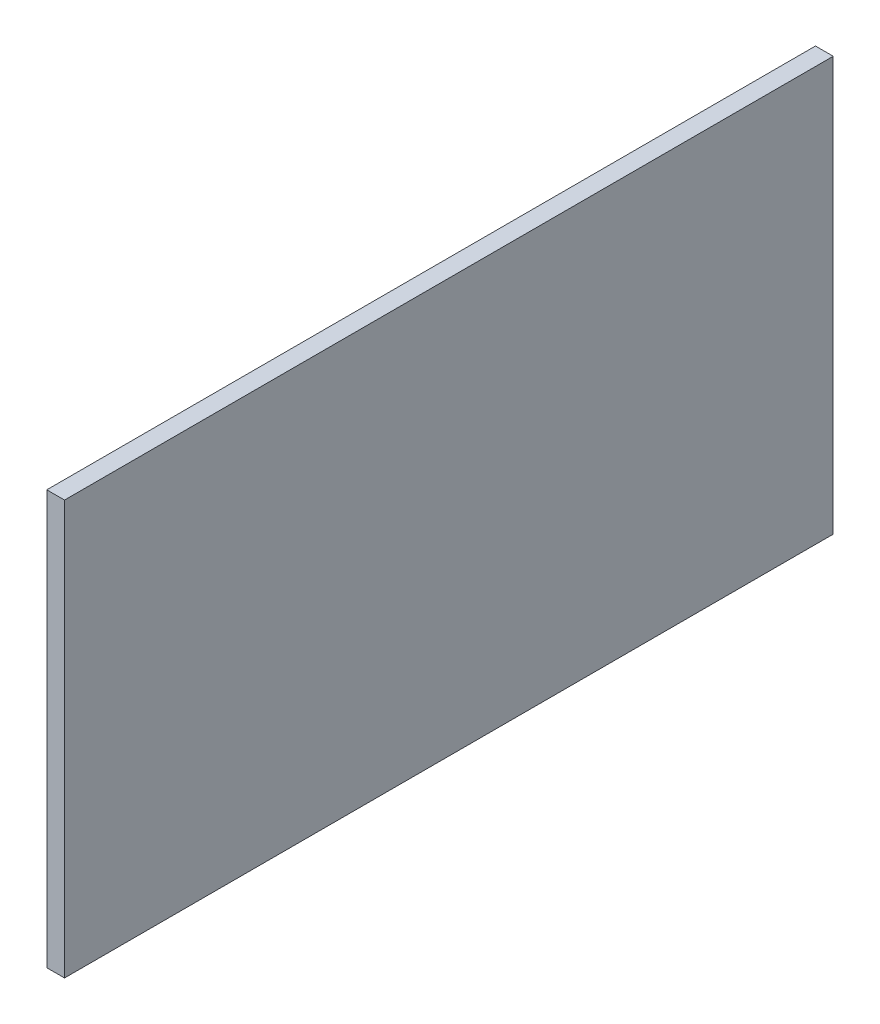
from build123d import *

# Parameters (mm, degrees)
SKETCH1_W           = 130
SKETCH1_H           = 70
BOSS_EXTRUDE1_DEPTH = 3


with BuildPart() as part:
    # Sketch1 → Boss-Extrude1 (new body)
    with BuildSketch(Plane(origin=(0, 0, 0), x_dir=(0, 0, -1), z_dir=(1, 0, 0))):
        with Locations((-6.240346154, 35)):
            Rectangle(SKETCH1_W, SKETCH1_H)
    extrude(amount=BOSS_EXTRUDE1_DEPTH)


solid = part.part
